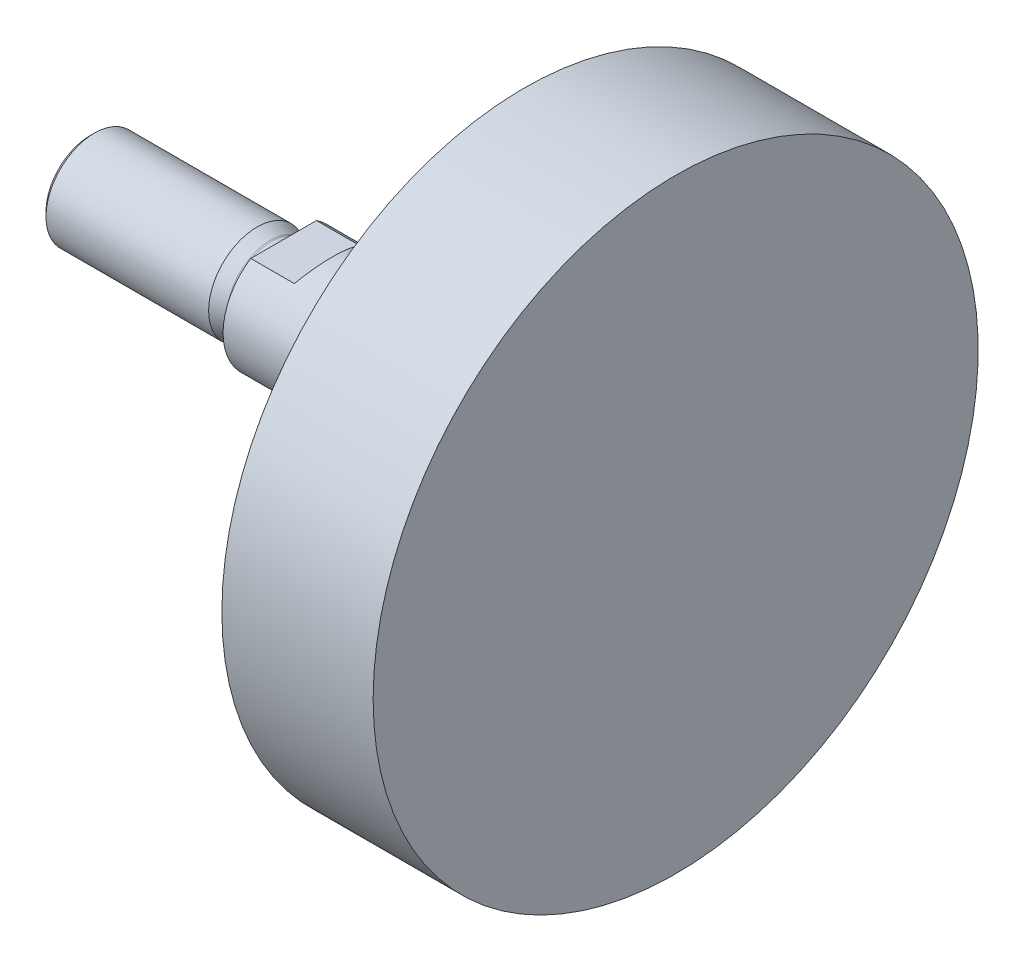
from build123d import *

# Parameters (mm, degrees)
SKETCH1_W               = 81
SKETCH1_H               = 12.5
SKETCH2_W               = 31.25
SKETCH2_H               = 62.5
CUT_EXTRUDE1_DEPTH      = 25
CUT_EXTRUDE1_DEPTH_BACK = 25


with BuildPart() as part:
    # Sketch1 → Revolve1 (revolve)
    with BuildSketch(Plane.XY):
        with Locations((29.5, 6.25)):
            Rectangle(SKETCH1_W, SKETCH1_H)
    revolve(axis=Axis((70, 0, 0), (-1, 0, 0)))

    # Sketch2 → Revolve2 (revolve)
    with BuildSketch(Plane.XY):
        with Locations((54.375, 31.25)):
            Rectangle(SKETCH2_W, SKETCH2_H)
    revolve(axis=Axis((70, 0, 0), (-1, 0, 0)))

    # Sketch3 → Revolve3 (revolve)
    with BuildSketch(Plane.XY):
        with BuildLine():
            Line((-51, 0), (-51, 9.08))
            Line((-51, 9.08), (-50.08, 10))
            Line((-50.08, 10), (-16.48485129, 10))
            Line((-16.48485129, 10), (-13.724269872, 8.995230534))
            ThreePointArc((-13.724269872, 8.995230534), (-13.597990898, 8.961394185), (-13.467754764, 8.95))
            Line((-13.467754764, 8.95), (-11.75, 8.95))
            ThreePointArc((-11.75, 8.95), (-11.219669914, 9.169669914), (-11, 9.7))
            Line((-11, 9.7), (-11, 10))
            Line((-11, 10), (-10, 10))
            Line((-10, 10), (-10, 0))
            Line((-10, 0), (-51, 0))
        make_face()
    revolve(axis=Axis((-10, 0, 0), (-1, 0, 0)))

    # Sketch4 → Cut-Extrude1 (cut, two sides: drawn at the far end of the back side and taken through both)
    with BuildSketch(Plane.XY.offset(-CUT_EXTRUDE1_DEPTH_BACK)):
        Polygon((-67, -28), (8.103629711, -28), (-2, -10.5), (-11, -10.5), (-11, -15.5), (-56, -15.5), (-56, 15.5), (-11, 15.5), (-11, 10.5), (-2, 10.5), (8.103629711, 28), (-67, 28), align=None)
    extrude(amount=CUT_EXTRUDE1_DEPTH + CUT_EXTRUDE1_DEPTH_BACK, mode=Mode.SUBTRACT)


solid = part.part
